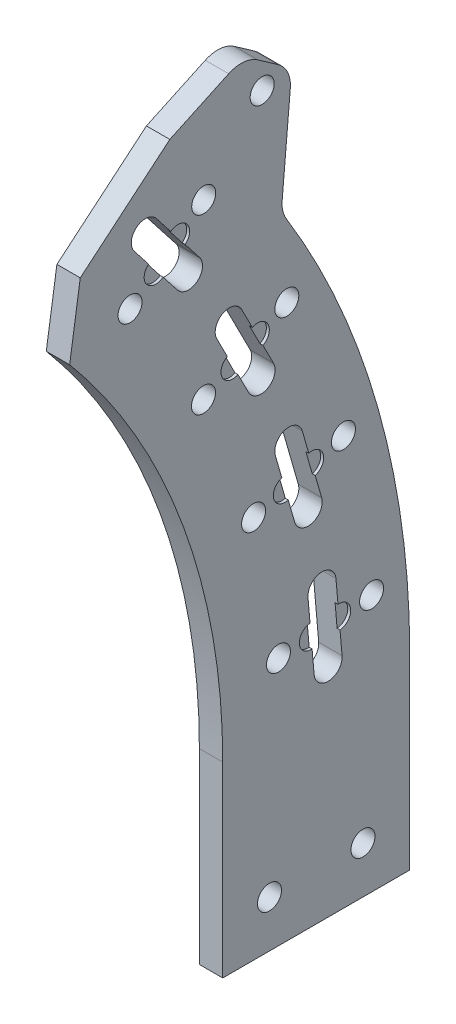
from build123d import *

# Parameters (mm, degrees)
SKETCH1_R               = 3.2639
BOSS_EXTRUDE1_DEPTH     = 6.35
SKETCH6_R               = 3.2639
CUT_EXTRUDE1_DEPTH      = 7.35
CUT_EXTRUDE2_START      = -0.79375
CUT_EXTRUDE2_DEPTH      = 10.82675
CIRPATTERN1_COUNT       = 4
CIRPATTERN1_ANGLE       = 33
BOSS_EXTRUDE2_DEPTH     = 6.35
SKETCH9_R               = 3.2639
CUT_EXTRUDE3_DEPTH      = 1
CUT_EXTRUDE3_DEPTH_BACK = 7.35
FILLET2_R               = 7.9375


with BuildPart() as part:
    # Sketch1 → Boss-Extrude1 (new body)
    with BuildSketch(Plane(origin=(0, 0, 0), x_dir=(0, 0, -1), z_dir=(1, 0, 0))):
        with BuildLine():
            Line((177.8, 0), (177.8, -50.8))
            Line((177.8, -50.8), (228.6, -50.8))
            Line((228.6, -50.8), (228.6, 0))
            ThreePointArc((228.6, 0), (214.813733112, 78.185804764), (175.117759697, 146.941247574))
            Line((175.117759697, 146.941247574), (163.413376386, 153.69877643))
            Line((163.413376386, 153.69877643), (139.091465317, 133.290269822))
            Line((139.091465317, 133.290269822), (136.202701987, 114.287637002))
            ThreePointArc((136.202701987, 114.287637002), (167.077347976, 60.811181483), (177.8, 0))
        make_face()
        with Locations((190.5, -38.1)):
            Circle(SKETCH1_R, mode=Mode.SUBTRACT)
        with Locations((215.9, -38.1)):
            Circle(SKETCH1_R, mode=Mode.SUBTRACT)
    extrude(amount=BOSS_EXTRUDE1_DEPTH)

    # Sketch6 → Cut-Extrude1 (cut, through all)
    with BuildSketch(Plane(origin=(6.35, 0, 0), x_dir=(0, 0, -1), z_dir=(1, 0, 0))):
        with Locations((192.938008153, 16.879888477)):
            Circle(SKETCH6_R)
        with Locations((218.241353484, 19.093644342)):
            Circle(SKETCH6_R)
        with Locations((186.172358961, 53.384064888)):
            Circle(SKETCH6_R)
        with Locations((210.588406038, 60.385253726)):
            Circle(SKETCH6_R)
        with Locations((172.565688572, 87.926610037)):
            Circle(SKETCH6_R)
        with Locations((195.197254287, 99.45796873)):
            Circle(SKETCH6_R)
        with Locations((152.617982705, 119.238236234)):
            Circle(SKETCH6_R)
        with Locations((172.633455846, 134.876037707)):
            Circle(SKETCH6_R)
        with BuildLine():
            Line((192.092529624, 64.990498635), (197.343421252, 46.678463327))
            ThreePointArc((197.343421252, 46.678463327), (202.056006639, 44.066234591), (204.668235375, 48.778819979))
            Line((204.668235375, 48.778819979), (199.417343747, 67.090855286))
            ThreePointArc((199.417343747, 67.090855286), (194.704758359, 69.703084022), (192.092529624, 64.990498635))
        make_face()
        with BuildLine():
            Line((176.162477062, 100.449422723), (184.810996082, 83.475748437))
            ThreePointArc((184.810996082, 83.475748437), (189.935434743, 81.810717384), (191.600465797, 86.935156045))
            Line((191.600465797, 86.935156045), (182.951946777, 103.908830331))
            ThreePointArc((182.951946777, 103.908830331), (177.827508115, 105.573861384), (176.162477062, 100.449422723))
        make_face()
        with BuildLine():
            Line((200.964020569, 27.143457529), (202.624337469, 8.16594853))
            ThreePointArc((202.624337469, 8.16594853), (206.751902648, 4.70251011), (210.215341068, 8.83007529))
            Line((210.215341068, 8.83007529), (208.555024169, 27.807584289))
            ThreePointArc((208.555024169, 27.807584289), (204.427458989, 31.271022709), (200.964020569, 27.143457529))
        make_face()
        with BuildLine():
            Line((159.763864694, 136.908609619), (171.492215799, 121.897004763))
            ThreePointArc((171.492215799, 121.897004763), (170.835565049, 116.549013571), (165.487573857, 117.205664321))
            Line((165.487573857, 117.205664321), (153.759222752, 132.217269177))
            ThreePointArc((153.759222752, 132.217269177), (154.415873502, 137.56526037), (159.763864694, 136.908609619))
        make_face()
    extrude(amount=-CUT_EXTRUDE1_DEPTH, mode=Mode.SUBTRACT)

    # Sketch8 → Cut-Extrude2 (cut)
    with BuildSketch(Plane(origin=(6.35, 15.551634957, -177.756000954), x_dir=(0, 0.087155743, -0.996194698), z_dir=(1, 0, 0)).offset(CUT_EXTRUDE2_START)):
        with BuildLine():
            Line((31.75, 3.175), (24.13, 3.175))
            ThreePointArc((24.13, 3.175), (20.955, 0), (24.13, -3.175))
            Line((24.13, -3.175), (31.75, -3.175))
            ThreePointArc((31.75, -3.175), (34.925, 0), (31.75, 3.175))
        make_face()
    cut_extrude2 = extrude(amount=CUT_EXTRUDE2_DEPTH, mode=Mode.SUBTRACT)

    # CirPattern1: Cut-Extrude2 ×4 about axis
    cirpattern1_axis = Axis((0, 0, 0), (1, 0, 0))
    for i in range(1, CIRPATTERN1_COUNT):
        add(cut_extrude2.rotate(cirpattern1_axis, i * CIRPATTERN1_ANGLE / (CIRPATTERN1_COUNT - 1)), mode=Mode.SUBTRACT)

    # Sketch11 → Boss-Extrude2 (add)
    with BuildSketch(Plane(origin=(6.35, 0, 0), x_dir=(0, 0, -1), z_dir=(1, 0, 0))):
        with BuildLine():
            Line((183.556066953, 163.091467297), (163.413376386, 153.69877643))
            Line((163.413376386, 153.69877643), (175.117759697, 146.941247574))
            ThreePointArc((175.117759697, 146.941247574), (184.855029121, 134.486349525), (193.708175574, 121.388231372))
            Line((193.708175574, 121.388231372), (196.560105656, 153.98594137))
            Line((196.560105656, 153.98594137), (183.556066953, 163.091467297))
        make_face()
    extrude(amount=-BOSS_EXTRUDE2_DEPTH)

    # Sketch9 → Cut-Extrude3 (cut, two sides)
    with BuildSketch(Plane(origin=(6.35, 0, 0), x_dir=(0, 0, -1), z_dir=(1, 0, 0))) as cut_extrude3_sk:
        with Locations((188.512295871, 152.654247257)):
            Circle(SKETCH9_R)
    extrude(amount=CUT_EXTRUDE3_DEPTH, mode=Mode.SUBTRACT)
    extrude(cut_extrude3_sk.sketch, amount=-CUT_EXTRUDE3_DEPTH_BACK, mode=Mode.SUBTRACT)

    # Fillet2
    fillet2_edges = [part.edges().sort_by_distance(p)[0] for p in [
        (3.175, 153.98594137, -196.560105656),
        (3.175, 121.388231372, -193.708175574),
        (3.175, 163.091467297, -183.556066953),
    ]]
    fillet(fillet2_edges, radius=FILLET2_R)


solid = part.part
